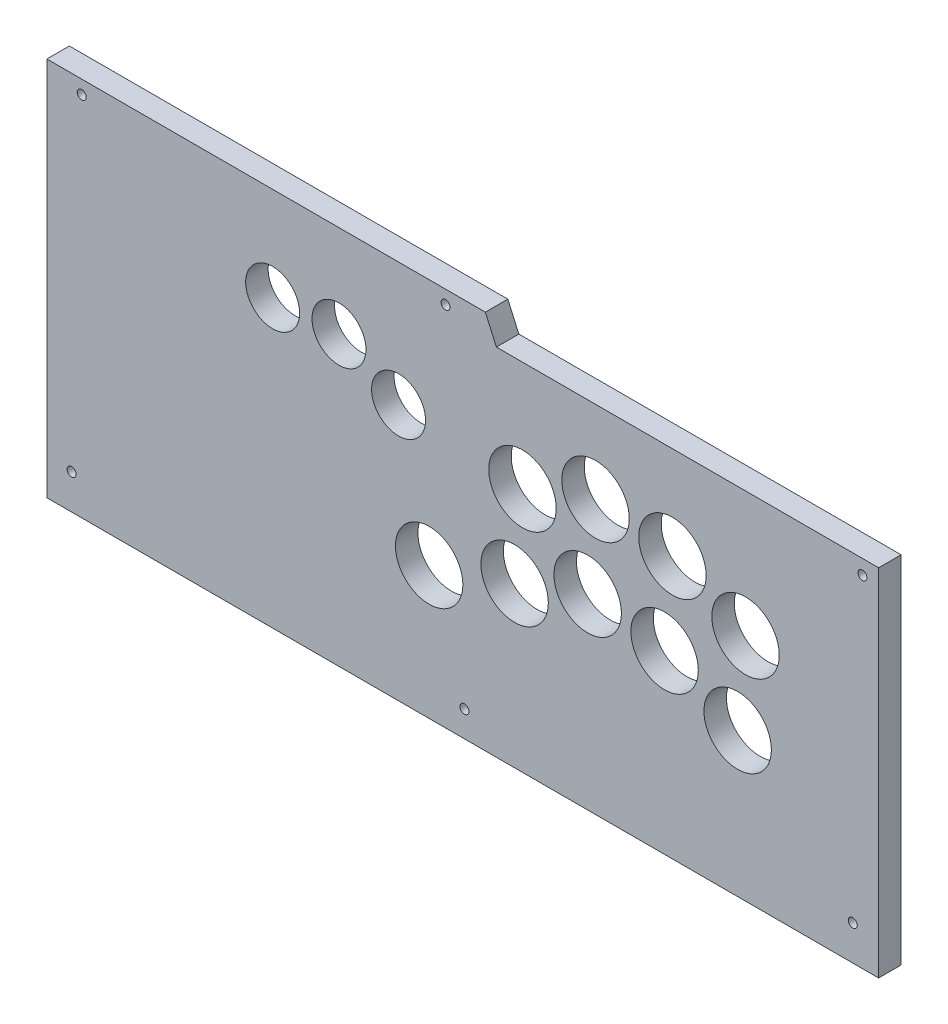
from build123d import *

# Parameters (mm, degrees)
BOSS_EXTRUDE1_DEPTH     = 5
SKETCH2_R               = 15
SKETCH2_R_2             = 12
SKETCH2_R_3             = 2
CUT_EXTRUDE1_DEPTH      = 6
CUT_EXTRUDE1_DEPTH_BACK = 6


with BuildPart() as part:
    # Sketch1 → Boss-Extrude1 (new body, symmetric)
    with BuildSketch(Plane.XY):
        Polygon((-184.95, 0), (184.95, 0), (184.95, 158), (14.95, 158), (10.05, 169), (-184.95, 169), align=None)
    extrude(amount=BOSS_EXTRUDE1_DEPTH, both=True)

    # Sketch2 → Cut-Extrude1 (cut, two sides)
    with BuildSketch(Plane.XY) as cut_extrude1_sk:
        with Locations((23.05, 71)):
            Circle(SKETCH2_R)
        with Locations((55.55, 83.2)):
            Circle(SKETCH2_R)
        with Locations((89.75, 78.4)):
            Circle(SKETCH2_R)
        with Locations((122.25, 64)):
            Circle(SKETCH2_R)
        with Locations((26.55, 109.2)):
            Circle(SKETCH2_R)
        with Locations((59.05, 121.4)):
            Circle(SKETCH2_R)
        with Locations((93.25, 116.6)):
            Circle(SKETCH2_R)
        with Locations((125.75, 102.2)):
            Circle(SKETCH2_R)
        with Locations((-14.95, 59)):
            Circle(SKETCH2_R)
        with Locations((-28.55, 114)):
            Circle(SKETCH2_R_2)
        with Locations((-55.05, 128)):
            Circle(SKETCH2_R_2)
        with Locations((-84.55, 127.3)):
            Circle(SKETCH2_R_2)
        with Locations((-7.65, 163)):
            Circle(SKETCH2_R_3)
        with Locations((-169.45, 163)):
            Circle(SKETCH2_R_3)
        with Locations((-173.95, 15.5)):
            Circle(SKETCH2_R_3)
        with Locations((0.75, 11.5)):
            Circle(SKETCH2_R_3)
        with Locations((173.45, 15.5)):
            Circle(SKETCH2_R_3)
        with Locations((177.75, 151.5)):
            Circle(SKETCH2_R_3)
    extrude(amount=CUT_EXTRUDE1_DEPTH, mode=Mode.SUBTRACT)
    extrude(cut_extrude1_sk.sketch, amount=-CUT_EXTRUDE1_DEPTH_BACK, mode=Mode.SUBTRACT)


solid = part.part
